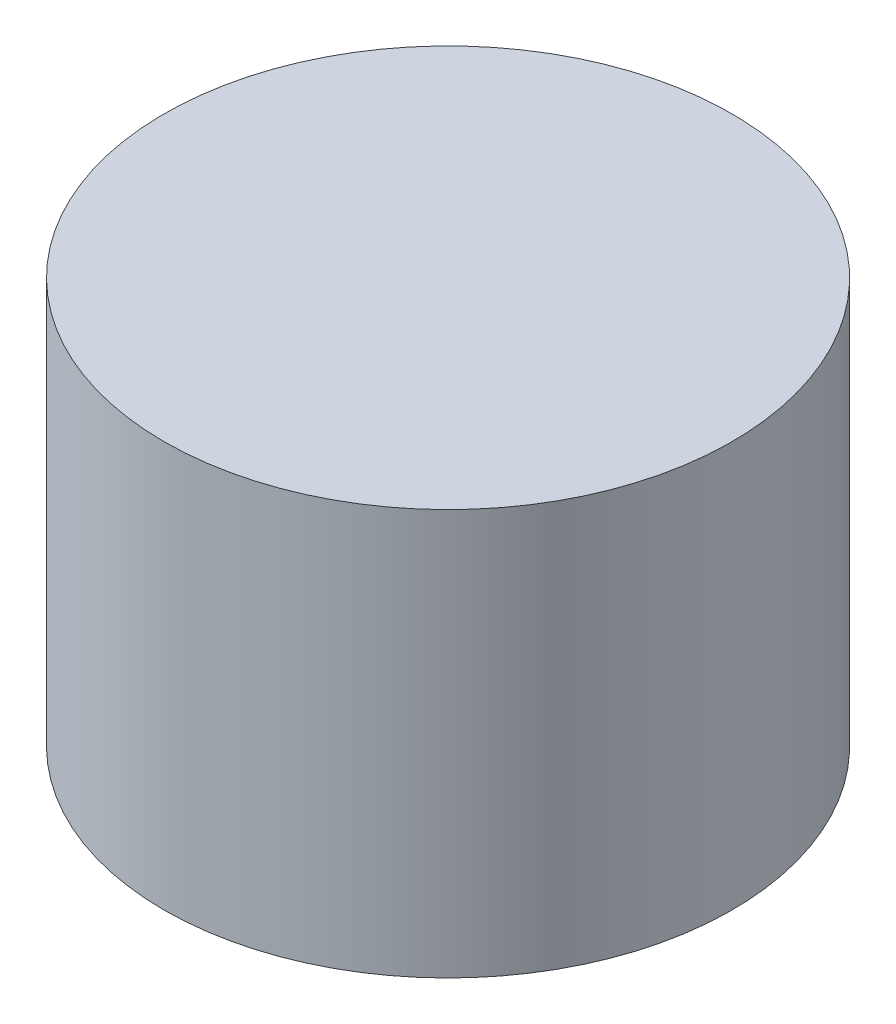
from build123d import *

# Parameters (mm, degrees)
SKETCH1_R           = 1.4
BOSS_EXTRUDE1_DEPTH = 2


with BuildPart() as part:
    # Sketch1 → Boss-Extrude1 (new body)
    with BuildSketch(Plane(origin=(0, 0, 0), x_dir=(1, 0, 0), z_dir=(0, 1, 0))):
        Circle(SKETCH1_R)
    extrude(amount=BOSS_EXTRUDE1_DEPTH)


solid = part.part
